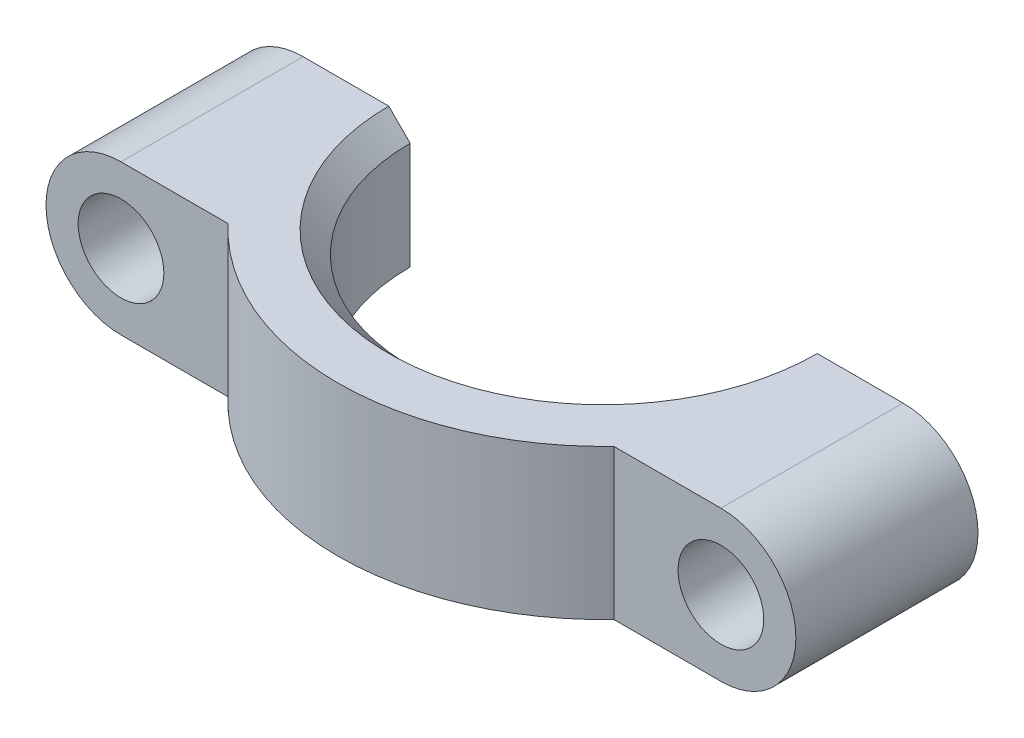
from build123d import *

# Parameters (mm, degrees)
CROQUIS1_R                = 2
SALIENTE_EXTRUIR1_DEPTH   = 8.5
SALIENTE_EXTRUIR1_2_DEPTH = 8.5
SALIENTE_EXTRUIR2_DEPTH   = 7
CHAFL_N1_SIZE             = 1


with BuildPart() as part:
    # Croquis1 → Saliente-Extruir1 (new body)
    with BuildSketch(Plane.XY):
        with BuildLine():
            Line((23, 3.5), (23, -3.5))
            Line((23, -3.5), (28, -3.5))
            ThreePointArc((28, -3.5), (30.474873734, -2.474873734), (31.5, 0))
            ThreePointArc((31.5, 0), (30.474873734, 2.474873734), (28, 3.5))
            Line((28, 3.5), (23, 3.5))
        make_face()
        with Locations((28, 0)):
            Circle(CROQUIS1_R, mode=Mode.SUBTRACT)
    extrude(amount=SALIENTE_EXTRUIR1_DEPTH)



with BuildPart() as body_2:
    # Croquis1 → Saliente-Extruir1 2 (new body)
    with BuildSketch(Plane.XY):
        with BuildLine():
            Line((5, -3.5), (5, 3.5))
            Line((5, 3.5), (0, 3.5))
            ThreePointArc((0, 3.5), (-3.5, 0), (0, -3.5))
            Line((0, -3.5), (5, -3.5))
        make_face()
        Circle(CROQUIS1_R, mode=Mode.SUBTRACT)
    extrude(amount=SALIENTE_EXTRUIR1_2_DEPTH)


with BuildPart() as part_1:
    add(part.part)

    add(body_2.part)  # Saliente-Extruir2 merges body 2
    # Croquis2 → Saliente-Extruir2 (add, through all)
    with BuildSketch(Plane.XZ.offset(3.5)):
        with BuildLine():
            Line((1.620581602, 2e-09), (5.000000002, 2e-09))
            ThreePointArc((5.000000002, 2e-09), (14.000000002, 9.000000002), (23.000000002, 2e-09))
            Line((23.000000002, 2e-09), (26.379418402, 2e-09))
            ThreePointArc((26.379418402, 2e-09), (14.000000002, 12.379418402), (1.620581602, 2e-09))
        make_face()
    extrude(amount=-SALIENTE_EXTRUIR2_DEPTH)

    # Chaflán1
    chafl_n1_edges = [part_1.edges().sort_by_distance(p)[0] for p in [
        (14.000000002, 3.5, 9.000000002),
        (14.000000002, -3.5, 9.000000002),
    ]]
    chamfer(chafl_n1_edges, length=CHAFL_N1_SIZE)


solid = part_1.part
